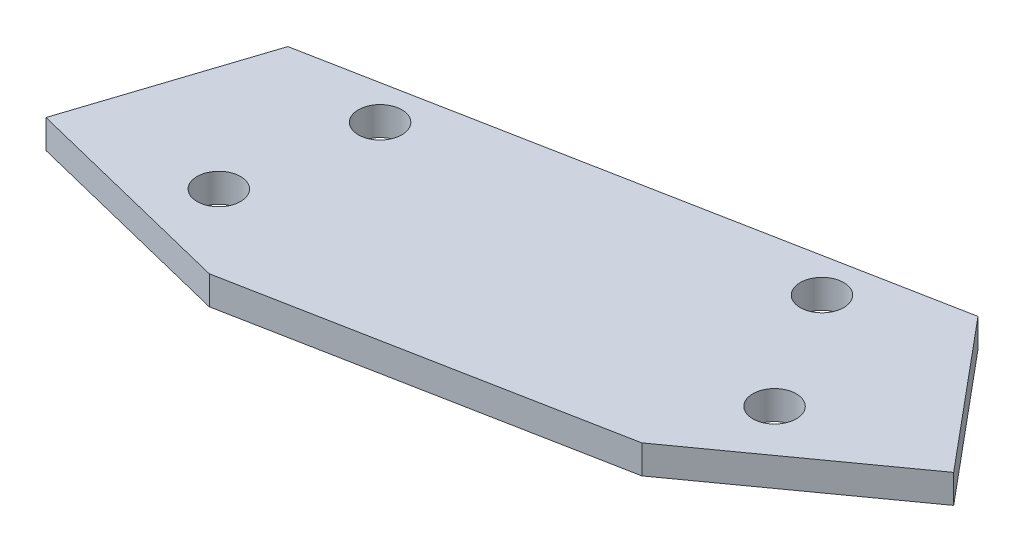
from build123d import *

# Parameters (mm, degrees)
SKETCH_2_R      = 1.52
EXTRUDE_2_DEPTH = 2


with BuildPart() as part:
    # 草图2 → 凸台-拉伸2 (new body)
    with BuildSketch(Plane(origin=(0, 0, 0), x_dir=(1, 0, 0), z_dir=(0, 1, 0))):
        Polygon((117.133278723, 13.653196573), (157.596462546, 21.44082227), (166.191748342, 11.144977596), (153.499211008, 2.030328902), (128.142526142, -2.849869635), (112.973576354, 0.902501232), align=None)
        with Locations((124.942788747, 12.292478307)):
            Circle(SKETCH_2_R, mode=Mode.SUBTRACT)
        with Locations((123.343028663, 2.614316014)):
            Circle(SKETCH_2_R, mode=Mode.SUBTRACT)
        with Locations((150.849906034, 17.278614174)):
            Circle(SKETCH_2_R, mode=Mode.SUBTRACT)
        with Locations((155.927676671, 8.885622868)):
            Circle(SKETCH_2_R, mode=Mode.SUBTRACT)
    extrude(amount=EXTRUDE_2_DEPTH)


solid = part.part
